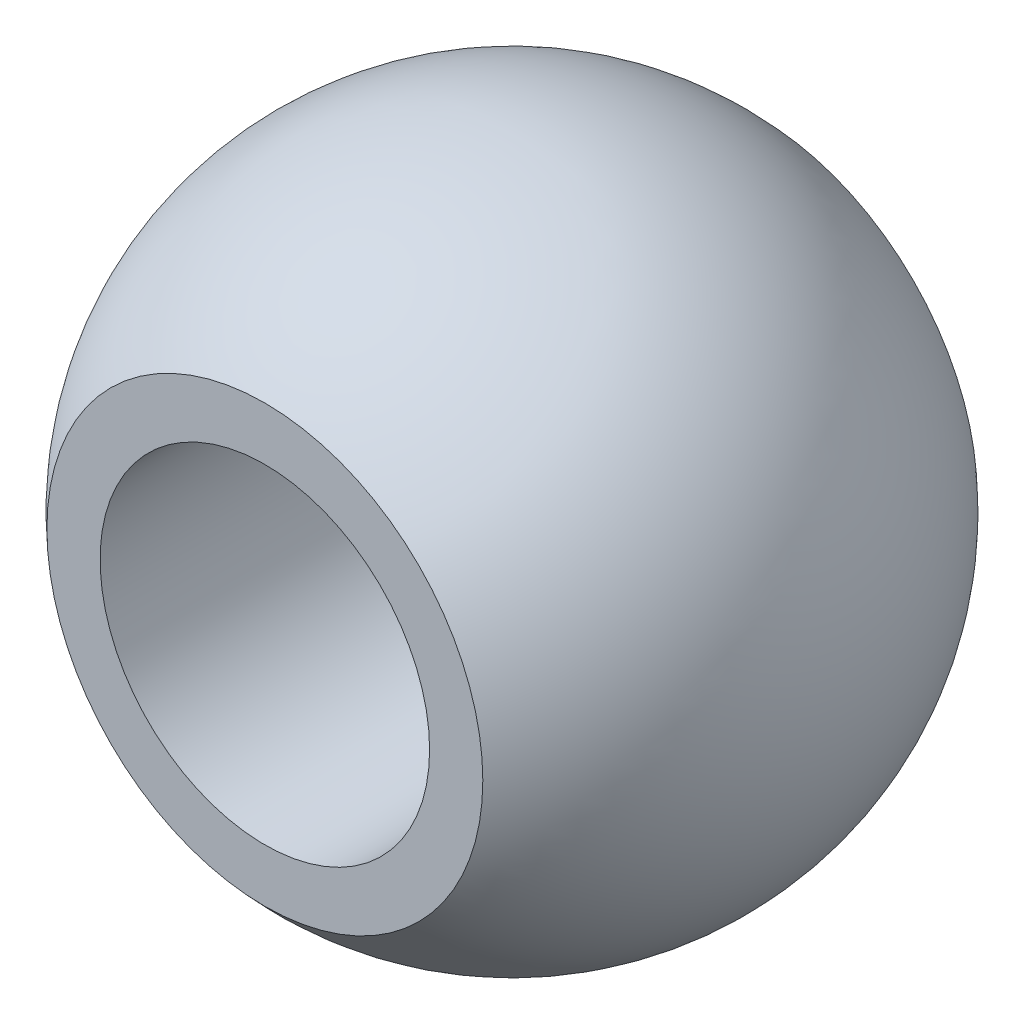
from build123d import *

# Parameters (mm, degrees)
SKETCH2_R          = 4
CUT_EXTRUDE1_DEPTH = 17


with BuildPart() as part:
    # Sketch1 → Revolve1 (revolve)
    with BuildSketch(Plane(origin=(0, 0, 0), x_dir=(1, 0, 0), z_dir=(0, 1, 0))):
        with BuildLine():
            Line((-5.291502622, 6), (0, 6))
            Line((0, 6), (0, -6))
            Line((0, -6), (-5.291502622, -6))
            ThreePointArc((-5.291502622, -6), (-8, 0), (-5.291502622, 6))
        make_face()
    revolve(axis=Axis((0, 0, -6), (0, 0, 1)))

    # Sketch2 → Cut-Extrude1 (cut)
    with BuildSketch(Plane.XY.offset(6)):
        Circle(SKETCH2_R)
    extrude(amount=-CUT_EXTRUDE1_DEPTH, mode=Mode.SUBTRACT)


solid = part.part
